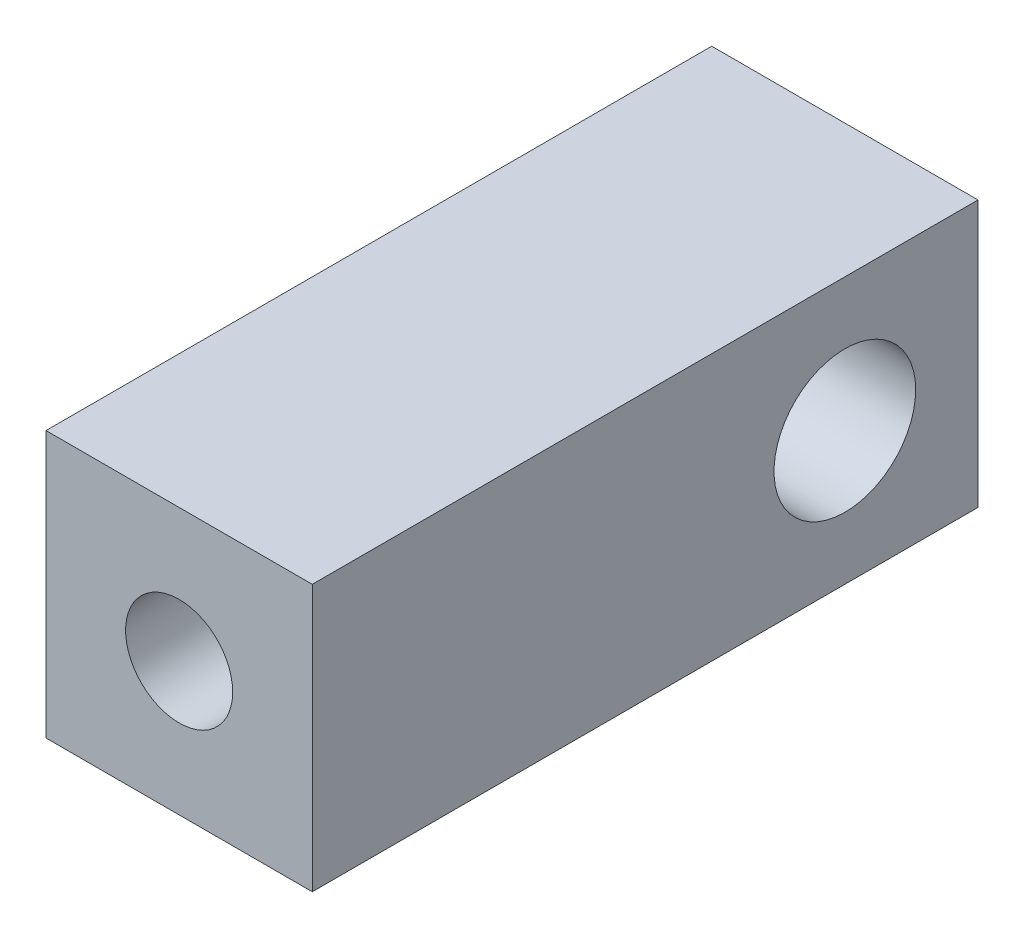
from build123d import *

# Parameters (mm, degrees)
SKETCH1_W                   = 31.75
SKETCH1_H                   = 12.7
BOSS_EXTRUDE1_DEPTH         = 12.7
F_1_4_20_TAPPED_HOLE1_D     = 5.1054
F_1_4_20_TAPPED_HOLE1_DEPTH = 16.51
F_1_4_20_TAPPED_HOLE1_TIP   = 1.533816902
SKETCH4_R                   = 3.3782
CUT_EXTRUDE1_DEPTH          = 13.7


with BuildPart() as part:
    # Sketch1 → Boss-Extrude1 (new body)
    with BuildSketch(Plane(origin=(0, 0, 0), x_dir=(0, 0, -1), z_dir=(1, 0, 0))):
        with Locations((15.875, 6.35)):
            Rectangle(SKETCH1_W, SKETCH1_H)
    extrude(amount=BOSS_EXTRUDE1_DEPTH)

    # 1/4-20 Tapped Hole1
    with Locations(Plane.XY):
        with Locations((6.35, 6.35)):
            Hole(F_1_4_20_TAPPED_HOLE1_D / 2, depth=F_1_4_20_TAPPED_HOLE1_DEPTH)
            with Locations((0, 0, -(F_1_4_20_TAPPED_HOLE1_DEPTH + F_1_4_20_TAPPED_HOLE1_TIP / 2))):  # 118° drill point
                Cone(0, F_1_4_20_TAPPED_HOLE1_D / 2, F_1_4_20_TAPPED_HOLE1_TIP, mode=Mode.SUBTRACT)

    # Sketch4 → Cut-Extrude1 (cut, through all)
    with BuildSketch(Plane(origin=(12.7, 0, 0), x_dir=(0, 0, -1), z_dir=(1, 0, 0))):
        with Locations((25.4, 6.35)):
            Circle(SKETCH4_R)
    extrude(amount=-CUT_EXTRUDE1_DEPTH, mode=Mode.SUBTRACT)


solid = part.part
